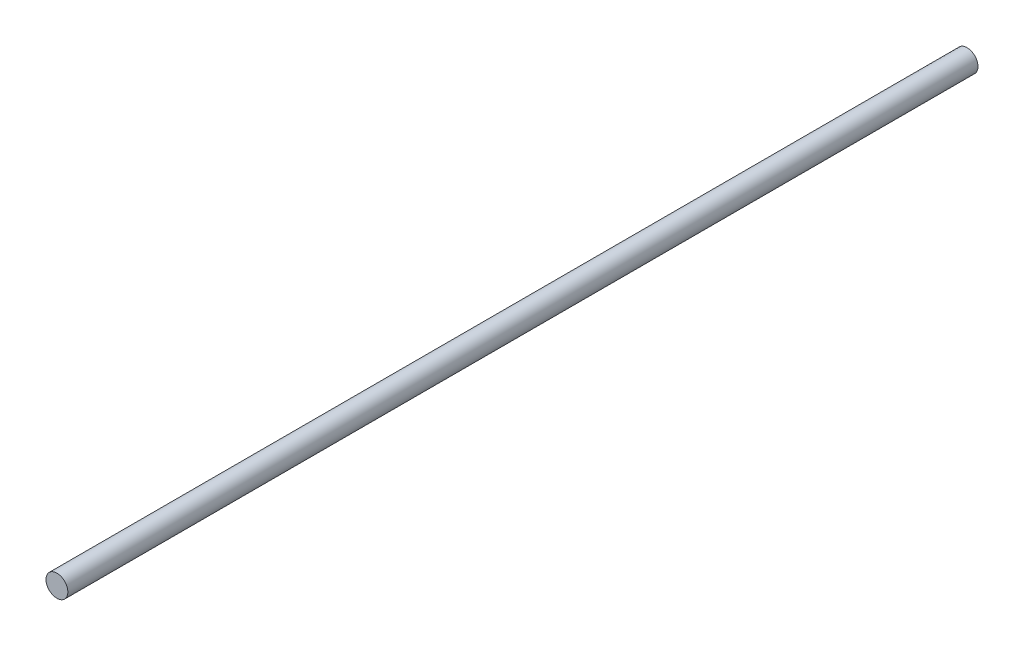
from build123d import *

# Parameters (mm, degrees)
CROQUIS1_R              = 3
SALIENTE_EXTRUIR1_DEPTH = 250


with BuildPart() as part:
    # Croquis1 → Saliente-Extruir1 (new body)
    with BuildSketch(Plane.XY):
        Circle(CROQUIS1_R)
    extrude(amount=SALIENTE_EXTRUIR1_DEPTH)


solid = part.part
